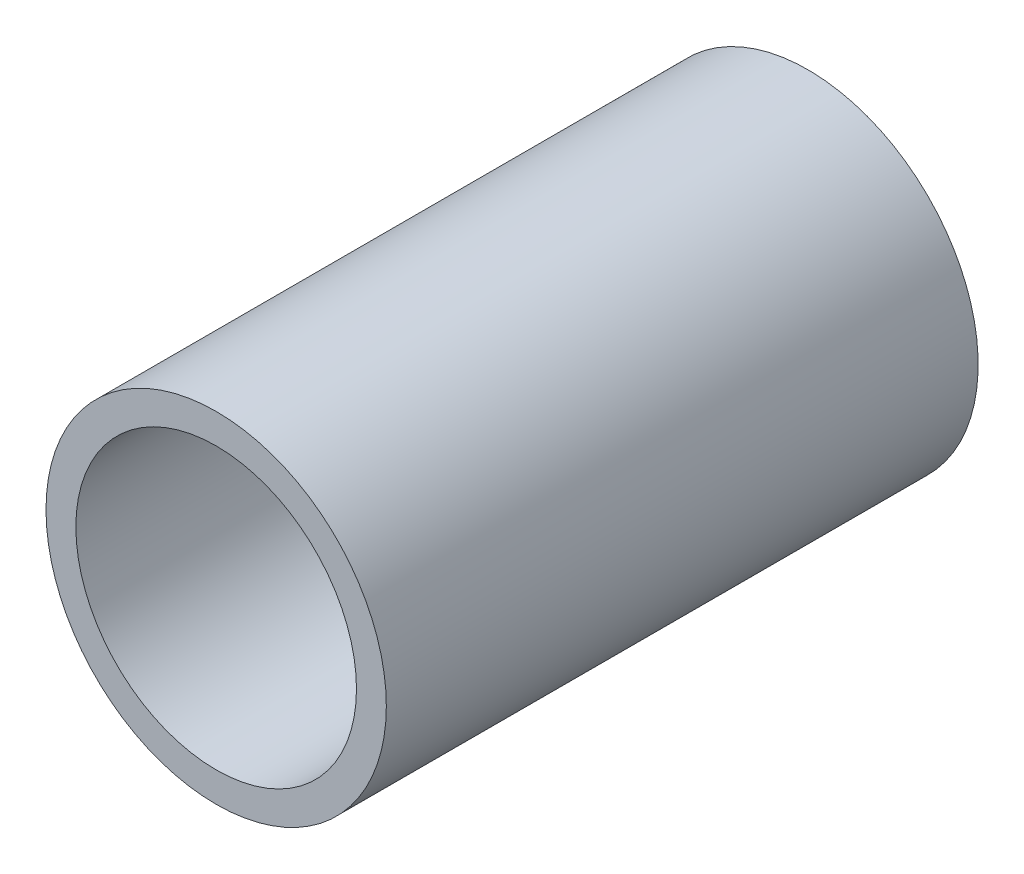
from build123d import *

# Parameters (mm, degrees)
SKETCH1_R           = 5.7
BOSS_EXTRUDE1_DEPTH = 31
SKETCH2_R           = 4.7
CUT_EXTRUDE1_DEPTH  = 33.302
SKETCH5_R           = 4.7
SKETCH5_R_2         = 4.192
BOSS_EXTRUDE3_DEPTH = 0.635
SKETCH8_R           = 5.7
SKETCH8_R_2         = 4.7
CUT_EXTRUDE2_DEPTH  = 11.176


with BuildPart() as part:
    # Sketch1 → Boss-Extrude1 (new body)
    with BuildSketch(Plane.XY):
        Circle(SKETCH1_R)
    extrude(amount=BOSS_EXTRUDE1_DEPTH)

    # Sketch2 → Cut-Extrude1 (cut)
    with BuildSketch(Plane.XY.offset(31)):
        Circle(SKETCH2_R)
    extrude(amount=-CUT_EXTRUDE1_DEPTH, mode=Mode.SUBTRACT)

    # Sketch5 → Boss-Extrude3 (add)
    with BuildSketch(Plane.XY.offset(19.824)):
        Circle(SKETCH5_R)
        Circle(SKETCH5_R_2, mode=Mode.SUBTRACT)
    extrude(amount=-BOSS_EXTRUDE3_DEPTH)

    # Sketch8 → Cut-Extrude2 (cut)
    with BuildSketch(Plane(origin=(0, 0, 0), x_dir=(-1, 0, 0), z_dir=(0, 0, -1))):
        Circle(SKETCH8_R)
        Circle(SKETCH8_R_2, mode=Mode.SUBTRACT)
    extrude(amount=-CUT_EXTRUDE2_DEPTH, mode=Mode.SUBTRACT)


solid = part.part
